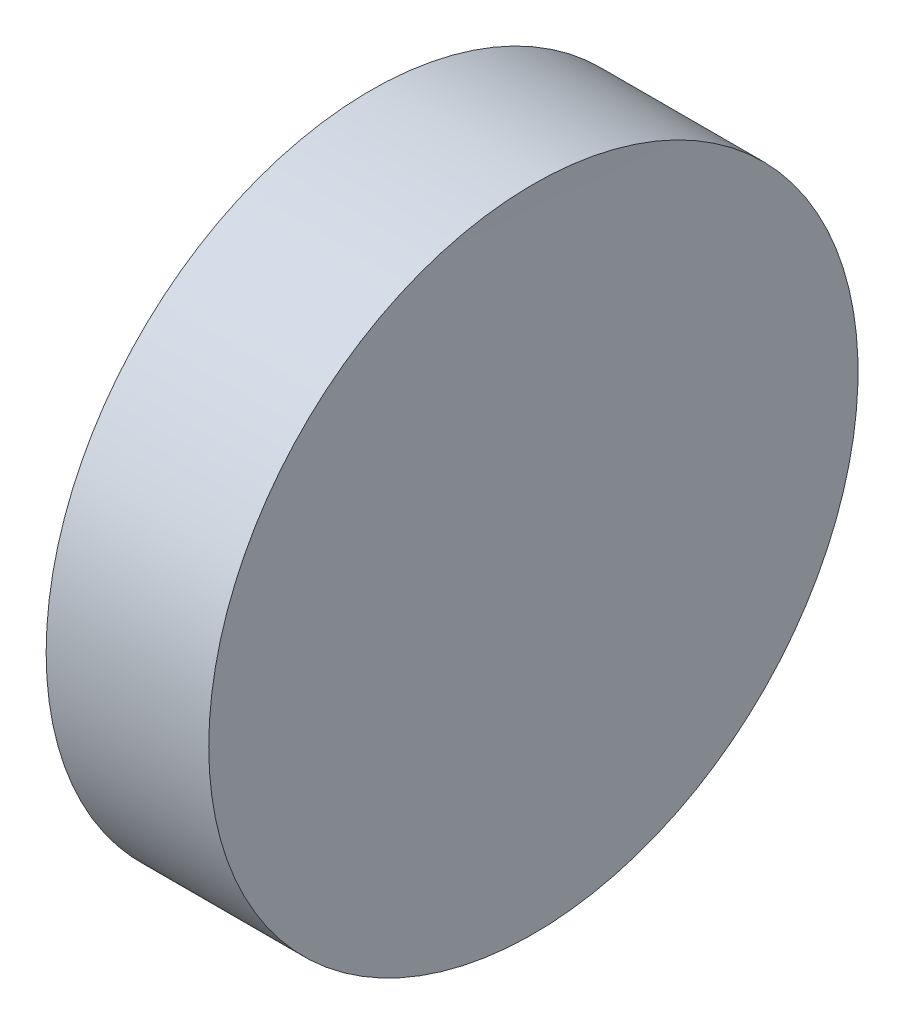
from build123d import *


with BuildPart() as part:
    # 草图1 → 旋转1 (revolve)
    with BuildSketch(Plane(origin=(0, 0, 0), x_dir=(1, 0, 0), z_dir=(0, 1, 0)), mode=Mode.PRIVATE) as revolve_1_sk:
        with BuildLine():
            Line((0, 0), (3.14, 0))
            ThreePointArc((3.14, 0), (3.150081133, 3.175064016), (3.180324126, 6.35))
            Line((3.180324126, 6.35), (0, 6.35))
            Line((0, 6.35), (0, 0))
        make_face()
    revolve(revolve_1_sk.sketch.rotate(Axis((0, 0, 0), (1, 0, 0)), 180), axis=Axis((0, 0, 0), (1, 0, 0)))  # turned: the seam where the file's is


solid = part.part
